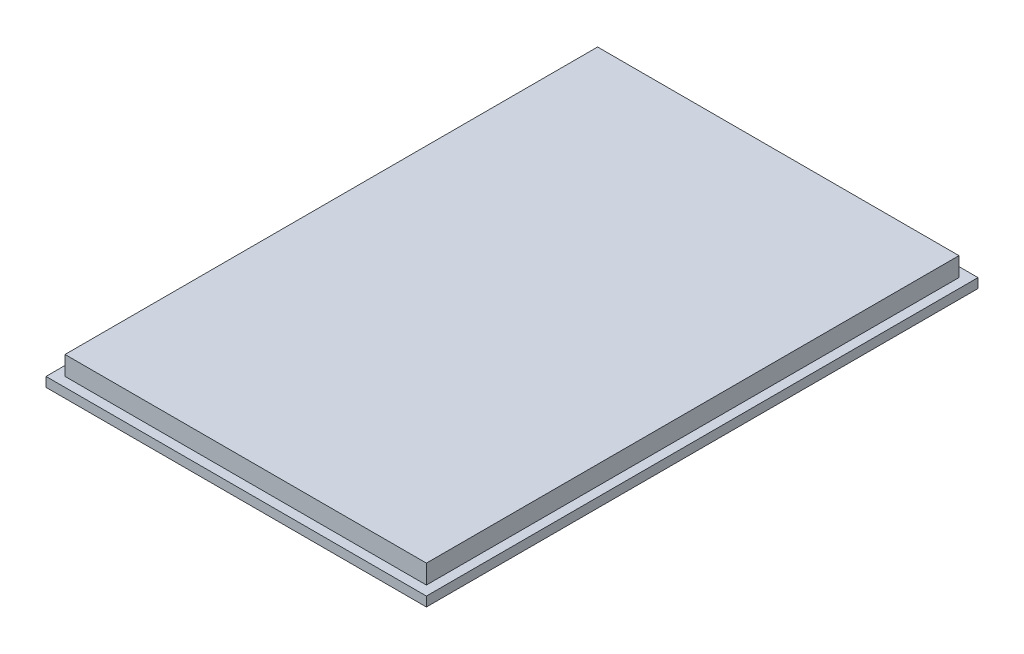
from build123d import *

# Parameters (mm, degrees)
SKETCH2_W           = 200
SKETCH2_H           = 290
BOSS_EXTRUDE1_DEPTH = 5
SKETCH3_W           = 190
SKETCH3_H           = 280
BOSS_EXTRUDE2_DEPTH = 10


with BuildPart() as part:
    # Sketch2 → Boss-Extrude1 (new body)
    with BuildSketch(Plane(origin=(0, 0, 0), x_dir=(1, 0, 0), z_dir=(0, 1, 0))):
        Rectangle(SKETCH2_W, SKETCH2_H)
    extrude(amount=BOSS_EXTRUDE1_DEPTH)

    # Sketch3 → Boss-Extrude2 (add)
    with BuildSketch(Plane(origin=(0, 5, 0), x_dir=(1, 0, 0), z_dir=(0, 1, 0))):
        Rectangle(SKETCH3_W, SKETCH3_H)
    extrude(amount=BOSS_EXTRUDE2_DEPTH)


solid = part.part
